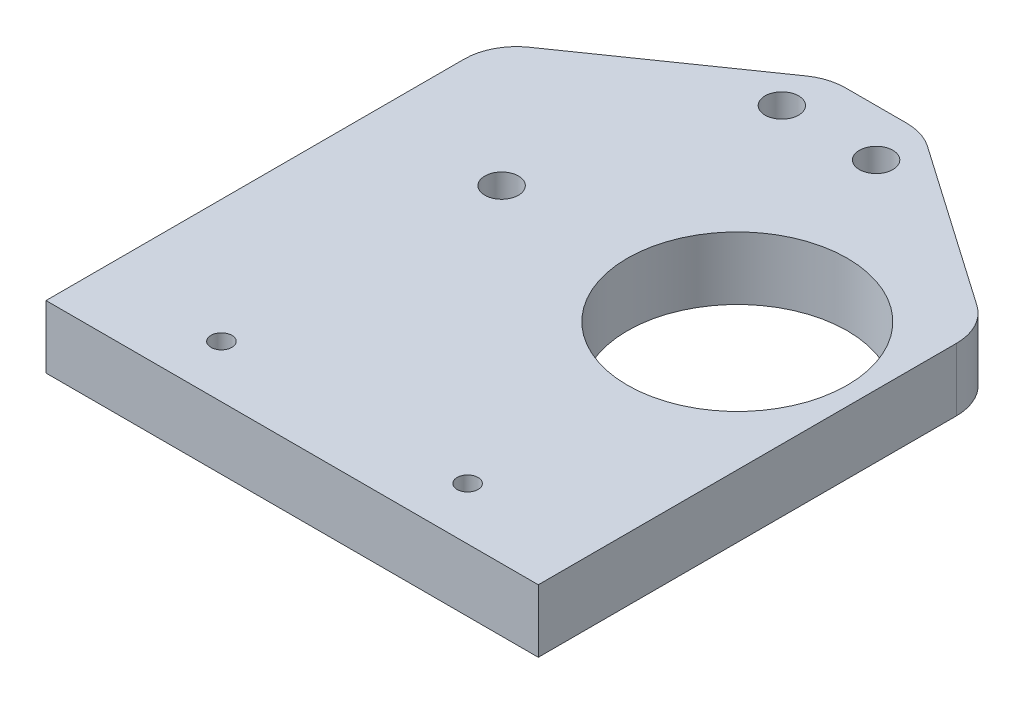
from build123d import *

# Parameters (mm, degrees)
SKETCH1_W           = 47
SKETCH1_H           = 45.75
SKETCH1_R           = 1.6
BOSS_EXTRUDE1_DEPTH = 6
CUT_EXTRUDE1_DEPTH  = 7
FILLET1_R           = 5
SKETCH3_R           = 10.5
CUT_EXTRUDE2_DEPTH  = 7
SKETCH4_W           = 47
SKETCH4_H           = 6
BOSS_EXTRUDE2_DEPTH = 10
SKETCH6_R           = 1
CUT_EXTRUDE3_DEPTH  = 7


with BuildPart() as part:
    # Sketch1 → Boss-Extrude1 (new body)
    with BuildSketch(Plane(origin=(0, 0, 0), x_dir=(1, 0, 0), z_dir=(0, 1, 0))):
        with Locations((0, 22.875)):
            Rectangle(SKETCH1_W, SKETCH1_H)
        with Locations((-4.5, 41.25)):
            Circle(SKETCH1_R, mode=Mode.SUBTRACT)
        with Locations((-11.25, 21.25)):
            Circle(SKETCH1_R, mode=Mode.SUBTRACT)
        with Locations((11.25, 21.25)):
            Circle(SKETCH1_R, mode=Mode.SUBTRACT)
        with Locations((4.5, 41.25)):
            Circle(SKETCH1_R, mode=Mode.SUBTRACT)
    extrude(amount=BOSS_EXTRUDE1_DEPTH)

    # Sketch2 → Cut-Extrude1 (cut, through all)
    with BuildSketch(Plane(origin=(0, 6, 0), x_dir=(1, 0, 0), z_dir=(0, 1, 0))):
        Polygon((23.5, 32.53), (4.5, 45.75), (23.5, 45.75), align=None)
        Polygon((-23.5, 32.53), (-4.5, 45.75), (-23.5, 45.75), align=None)
    extrude(amount=-CUT_EXTRUDE1_DEPTH, mode=Mode.SUBTRACT)

    # Fillet1
    fillet1_edges = [part.edges().sort_by_distance(p)[0] for p in [
        (23.5, 3, -32.53),
        (4.5, 3, -45.75),
        (-23.5, 3, -32.53),
        (-4.5, 3, -45.75),
    ]]
    fillet(fillet1_edges, radius=FILLET1_R)

    # Sketch3 → Cut-Extrude2 (cut, through all)
    with BuildSketch(Plane.XZ):
        with Locations((11.25, -21.25)):
            Circle(SKETCH3_R)
    extrude(amount=-CUT_EXTRUDE2_DEPTH, mode=Mode.SUBTRACT)

    # Sketch4 → Boss-Extrude2 (add)
    with BuildSketch(Plane.XY):
        with Locations((0, 3)):
            Rectangle(SKETCH4_W, SKETCH4_H)
    extrude(amount=BOSS_EXTRUDE2_DEPTH)

    # Sketch6 → Cut-Extrude3 (cut, through all)
    with BuildSketch(Plane(origin=(0, 6, 0), x_dir=(1, 0, 0), z_dir=(0, 1, 0))):
        with Locations((-11.75, -5)):
            Circle(SKETCH6_R)
        with Locations((11.75, -5)):
            Circle(SKETCH6_R)
    extrude(amount=-CUT_EXTRUDE3_DEPTH, mode=Mode.SUBTRACT)


solid = part.part
